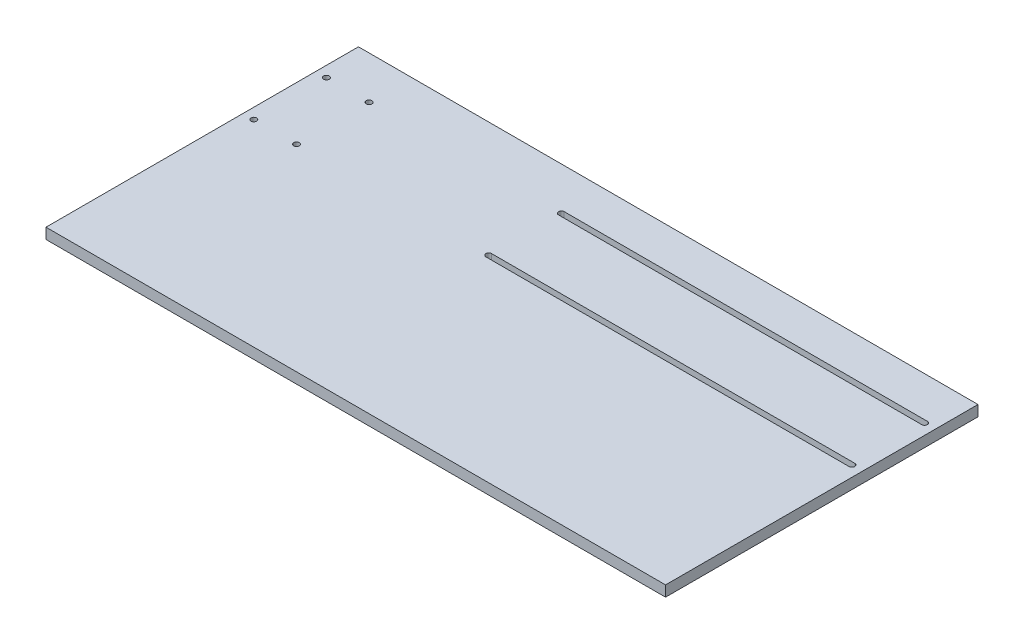
from build123d import *

# Parameters (mm, degrees)
SKETCH1_W           = 736.6
SKETCH1_H           = 371.475
BOSS_EXTRUDE1_DEPTH = 12.7
SKETCH2_R           = 3.3782
CUT_EXTRUDE1_DEPTH  = 13.7


with BuildPart() as part:
    # Sketch1 → Boss-Extrude1 (new body)
    with BuildSketch(Plane(origin=(0, 0, 0), x_dir=(1, 0, 0), z_dir=(0, 1, 0))):
        Rectangle(SKETCH1_W, SKETCH1_H)
    extrude(amount=BOSS_EXTRUDE1_DEPTH)

    # Sketch2 → Cut-Extrude1 (cut, through all)
    with BuildSketch(Plane(origin=(0, 12.7, 0), x_dir=(1, 0, 0), z_dir=(0, 1, 0))):
        with Locations((-355.6, 134.9375)):
            Circle(SKETCH2_R)
        with Locations((-355.6, 48.5775)):
            Circle(SKETCH2_R)
        with Locations((-304.8, 48.5775)):
            Circle(SKETCH2_R)
        with Locations((-304.8, 134.9375)):
            Circle(SKETCH2_R)
        with BuildLine():
            Line((-76.2, 138.3157), (355.6, 138.3157))
            ThreePointArc((355.6, 138.3157), (358.9782, 134.9375), (355.6, 131.5593))
            Line((355.6, 131.5593), (-76.2, 131.5593))
            ThreePointArc((-76.2, 131.5593), (-79.5782, 134.9375), (-76.2, 138.3157))
        make_face()
        with BuildLine():
            Line((-76.2, 51.9557), (355.6, 51.9557))
            ThreePointArc((355.6, 51.9557), (358.9782, 48.5775), (355.6, 45.1993))
            Line((355.6, 45.1993), (-76.2, 45.1993))
            ThreePointArc((-76.2, 45.1993), (-79.5782, 48.5775), (-76.2, 51.9557))
        make_face()
    extrude(amount=-CUT_EXTRUDE1_DEPTH, mode=Mode.SUBTRACT)


solid = part.part
